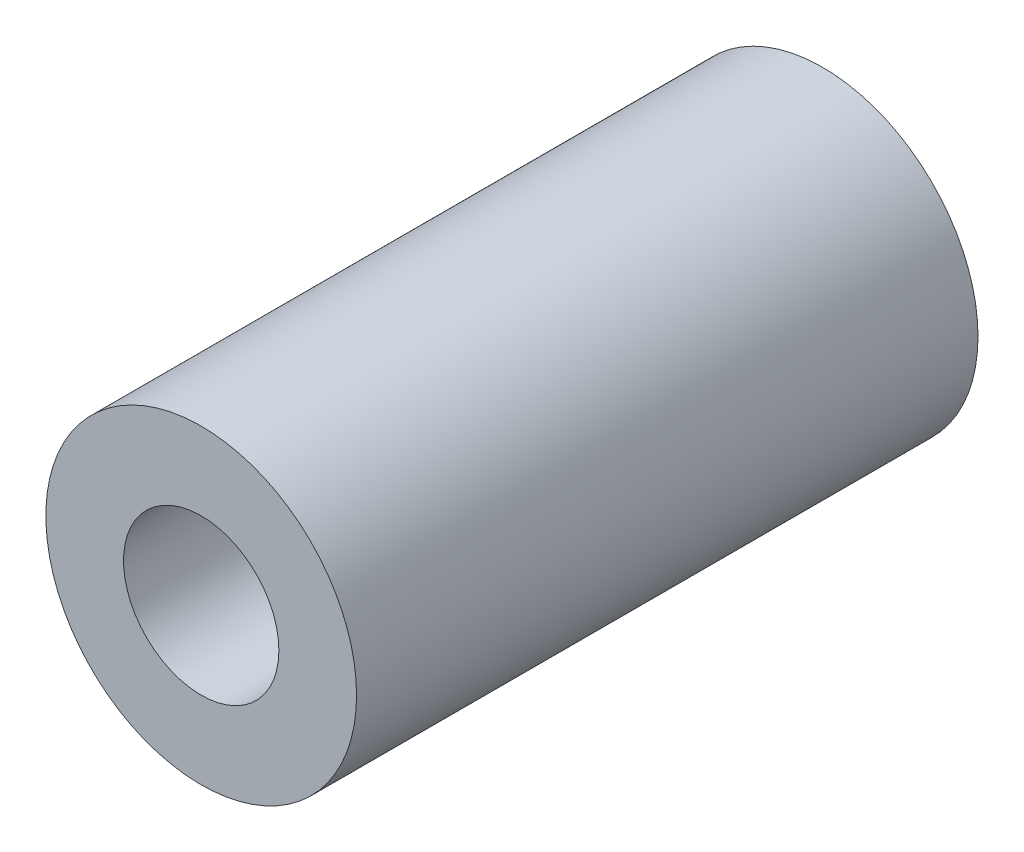
from build123d import *

# Parameters (mm, degrees)
SKETCH1_R           = 3.175
SKETCH1_R_2         = 1.5875
BOSS_EXTRUDE1_DEPTH = 12.7


with BuildPart() as part:
    # Sketch1 → Boss-Extrude1 (new body)
    with BuildSketch(Plane.XY):
        Circle(SKETCH1_R)
        Circle(SKETCH1_R_2, mode=Mode.SUBTRACT)
    extrude(amount=BOSS_EXTRUDE1_DEPTH)


solid = part.part
